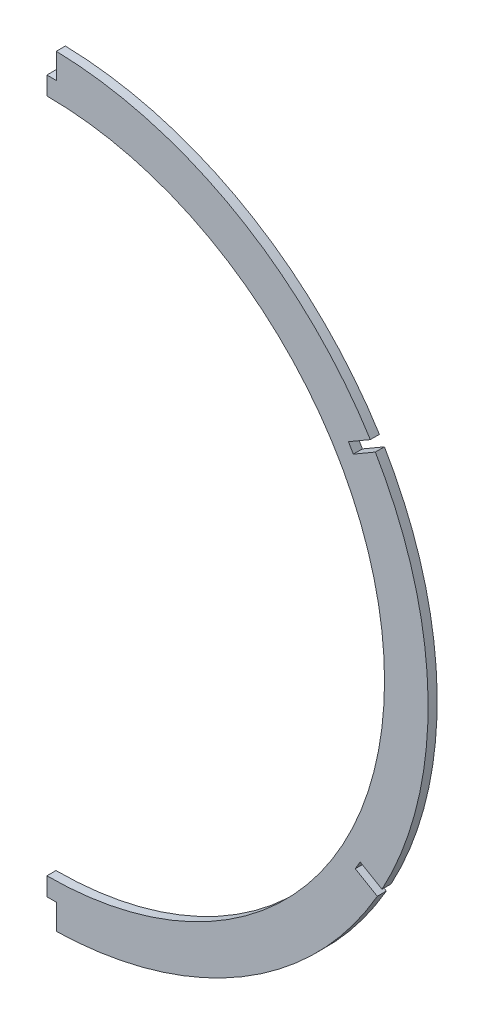
from build123d import *

# Parameters (mm, degrees)
BOSS_EXTRUDE1_DEPTH = 1.5875
CUT_EXTRUDE1_DEPTH  = 3.175
FILLET1_R           = 8.89
SKETCH3_W           = 234.443386257
SKETCH3_H           = 422.563019086
CUT_EXTRUDE2_DEPTH  = 134.35
CUT_EXTRUDE3_DEPTH  = 4.175


with BuildPart() as part:
    # Sketch1 → Boss-Extrude1 (new body, symmetric)
    with BuildSketch(Plane.XY):
        with BuildLine():
            Line((-120.187952283, -34.272453), (-93.24718392, -61.213221363))
            Line((-93.24718392, -61.213221363), (-94.292689271, -70.797689271))
            ThreePointArc((-94.292689271, -70.797689271), (-77.124658044, -85.289234251), (-57.767453, -96.692952283))
            ThreePointArc((-57.767453, -96.692952283), (94.292689271, 117.787689271), (-120.187952283, -34.272453))
        make_face()
    extrude(amount=BOSS_EXTRUDE1_DEPTH, both=True)

    # Sketch2 → Cut-Extrude1 (cut)
    with BuildSketch(Plane.XY.offset(1.5875)):
        with BuildLine():
            Line((-77.304798152, -55.60299244), (-78.320318415, -64.912577861))
            ThreePointArc((-78.320318415, -64.912577861), (94.997930523, 93.675946819), (-107.51910025, -25.388690342))
            Line((-107.51910025, -25.388690342), (-77.304798152, -55.60299244))
        make_face()
    extrude(amount=-CUT_EXTRUDE1_DEPTH, mode=Mode.SUBTRACT)

    # Fillet1
    fillet1_edges = [part.edges().sort_by_distance(p)[0] for p in [
        (-77.304798152, -55.60299244, 0),
        (-107.51910025, -25.388690342, 0),
        (-78.320318415, -64.912577861, 0),
        (-93.24718392, -61.213221363, -0.79375),
        (-120.187952283, -34.272453, -0.79375),
        (-94.292689271, -70.797689271, -0.79375),
    ]]
    fillet(fillet1_edges, radius=FILLET1_R)

    # Sketch3 → Cut-Extrude2 (cut, through all)
    with BuildSketch(Plane(origin=(0, 0, 0), x_dir=(0, 0, -1), z_dir=(1, 0, 0))):
        with Locations((10.168628802, 16.433452221)):
            Rectangle(SKETCH3_W, SKETCH3_H)
    extrude(amount=-CUT_EXTRUDE2_DEPTH, mode=Mode.SUBTRACT)

    # Sketch4 → Cut-Extrude3 (cut, through all)
    with BuildSketch(Plane(origin=(0, 0, -1.5875), x_dir=(-1, 0, 0), z_dir=(0, 0, -1))):
        with BuildLine():
            Line((-3.302, 156.804111827), (-3.302, 147.955))
            Line((-3.302, 147.955), (0, 147.955))
            Line((0, 147.955), (0, 156.845))
            ThreePointArc((0, 156.845), (-1.651126573, 156.834777565), (-3.302, 156.804111827))
        make_face()
        with BuildLine():
            Line((-105.489605782, 89.621888205), (-113.138876948, 94.076987949))
            ThreePointArc((-113.138876948, 94.076987949), (-114.023976238, 92.638006465), (-114.890774539, 91.187927443))
            Line((-114.890774539, 91.187927443), (-107.18979641, 86.702712453))
            Line((-107.18979641, 86.702712453), (-105.489605782, 89.621888205))
        make_face()
        with BuildLine():
            Line((-109.566752285, -35.631551273), (-117.216023462, -40.086650998))
            ThreePointArc((-117.216023462, -40.086650998), (-116.401122895, -41.566517726), (-115.567539805, -43.035942))
            Line((-115.567539805, -43.035942), (-107.866561664, -38.550727029))
            Line((-107.866561664, -38.550727029), (-109.566752285, -35.631551273))
        make_face()
        with BuildLine():
            Line((-3.302, -100.965), (-3.302, -109.814111827))
            ThreePointArc((-3.302, -109.814111827), (-1.651126573, -109.844777565), (0, -109.855))
            Line((0, -109.855), (0, -100.965))
            Line((0, -100.965), (-3.302, -100.965))
        make_face()
    extrude(amount=-CUT_EXTRUDE3_DEPTH, mode=Mode.SUBTRACT)


solid = part.part
